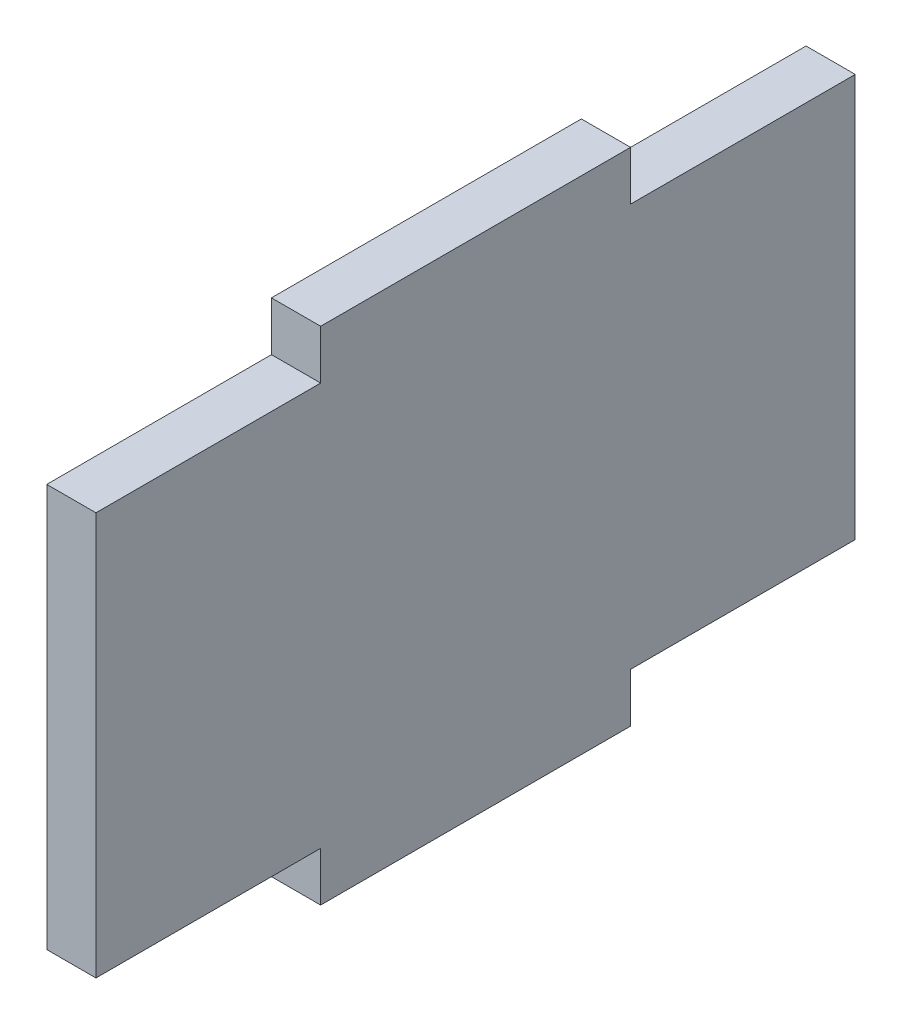
from build123d import *

# Parameters (mm, degrees)
SKETCH1_W           = 20
SKETCH1_H           = 3.175
BOSS_EXTRUDE1_DEPTH = 3.175


with BuildPart() as part:
    # Sketch1 → Boss-Extrude1 (new body)
    with BuildSketch(Plane(origin=(0, 0, 0), x_dir=(0, 0, -1), z_dir=(1, 0, 0))):
        with Locations((0, 14.5875)):
            Rectangle(SKETCH1_W, SKETCH1_H)
        Polygon((-24.5, 13), (-24.5, -13), (-10, -13), (10, -13), (24.5, -13), (24.5, 13), (10, 13), (-10, 13), align=None)
        with Locations((0, -14.5875)):
            Rectangle(SKETCH1_W, SKETCH1_H)
    extrude(amount=BOSS_EXTRUDE1_DEPTH)


solid = part.part
